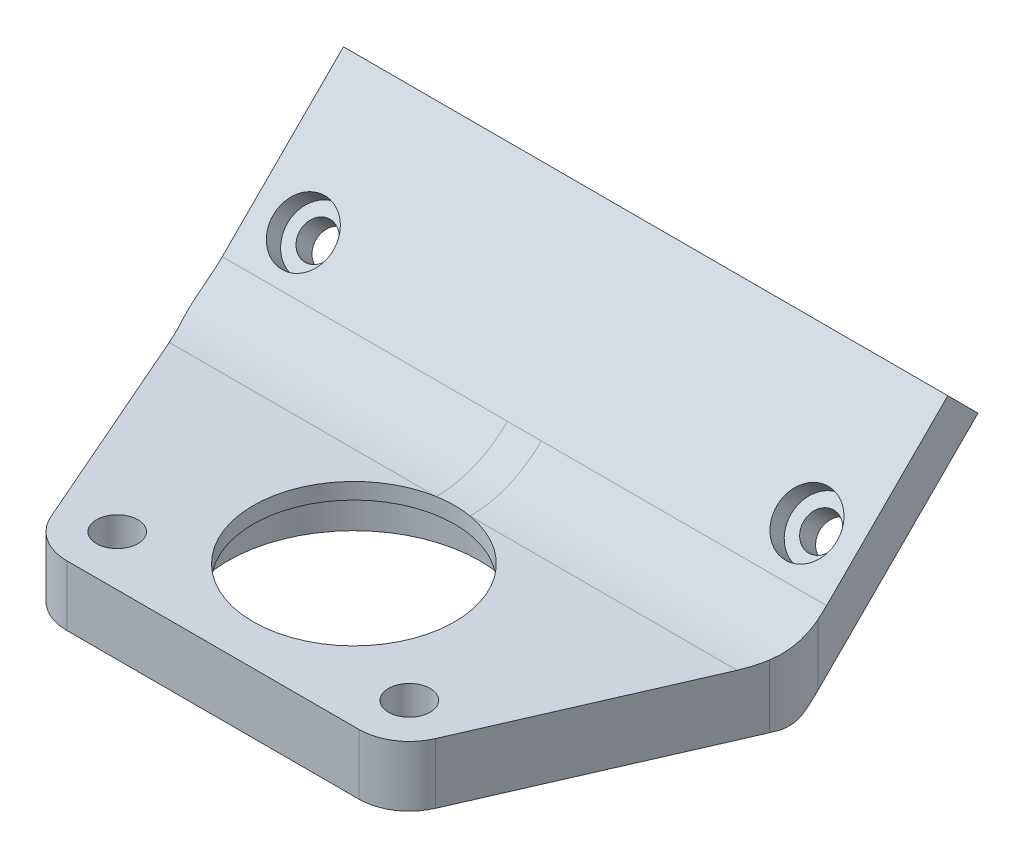
from build123d import *

# Parameters (mm, degrees)
SALIENTE_EXTRUIR1_DEPTH      = 30
SALIENTE_EXTRUIR1_DEPTH_BACK = 30
CROQUIS3_R                   = 1.75
CORTAR_EXTRUIR1_DEPTH        = 4.242641
CROQUIS4_R                   = 3
CORTAR_EXTRUIR2_DEPTH        = 2
CROQUIS5_R                   = 10
CROQUIS5_R_2                 = 1.75
CORTAR_EXTRUIR3_DEPTH        = 6
CROQUIS5_4_R                 = 12.5
CROQUIS5_4_R_2               = 10
CORTAR_EXTRUIR4_DEPTH        = 4.4
REDONDEO1_R                  = 10
REDONDEO2_R                  = 3
REDONDEO3_R                  = 10
CROQUIS6_R                   = 2.06
CORTAR_EXTRUIR5_DEPTH        = 4.2


with BuildPart() as part:
    # Croquis2 → Saliente-Extruir1 (new body, two sides)
    with BuildSketch(Plane(origin=(0, 0, 0), x_dir=(0, 0, -1), z_dir=(1, 0, 0))) as saliente_extruir1_sk:
        Polygon((0, 0), (-28, 0), (-28, 6), (0, 6), (14.960512242, 20.960512242), (17.960512242, 17.960512242), align=None)
    extrude(amount=SALIENTE_EXTRUIR1_DEPTH)
    extrude(saliente_extruir1_sk.sketch, amount=-SALIENTE_EXTRUIR1_DEPTH_BACK)

    # Croquis3 → Cortar-Extruir1 (cut)
    with BuildSketch(Plane(origin=(0, 0, 0), x_dir=(-1, 0, 0), z_dir=(0, -0.707106781, -0.707106781))):
        with Locations((-25, 12.7)):
            Circle(CROQUIS3_R)
        with Locations((25, 12.7)):
            Circle(CROQUIS3_R)
    extrude(amount=-CORTAR_EXTRUIR1_DEPTH, mode=Mode.SUBTRACT)

    # Croquis4 → Cortar-Extruir2 (cut)
    with BuildSketch(Plane(origin=(0, 3, 3), x_dir=(1, 0, 0), z_dir=(0, 0.707106781, 0.707106781))):
        with Locations((-25, 12.7)):
            Circle(CROQUIS4_R)
        with Locations((25, 12.7)):
            Circle(CROQUIS4_R)
    extrude(amount=-CORTAR_EXTRUIR2_DEPTH, mode=Mode.SUBTRACT)

    # Croquis5 → Cortar-Extruir3 (cut)
    with BuildSketch(Plane(origin=(0, 0, 0), x_dir=(-1, 0, 0), z_dir=(0, -1, 0))):
        with Locations((0, -14)):
            Circle(CROQUIS5_R)
        with Locations((14.5, -23)):
            Circle(CROQUIS5_R_2)
        with Locations((-14.5, -23)):
            Circle(CROQUIS5_R_2)
        with BuildLine():
            ThreePointArc((-19.082136833, -25.001005257), (-17.238153914, -27.1836005), (-14.5, -28))
            Line((-14.5, -28), (-30, -28))
            Line((-30, -28), (-30, 0))
            Line((-30, 0), (-19.082136833, -25.001005257))
        make_face()
        with BuildLine():
            Line((30, 0), (19.082136833, -25.001005257))
            ThreePointArc((19.082136833, -25.001005257), (17.238153914, -27.1836005), (14.5, -28))
            Line((14.5, -28), (30, -28))
            Line((30, -28), (30, 0))
        make_face()
    extrude(amount=-CORTAR_EXTRUIR3_DEPTH, mode=Mode.SUBTRACT)

    # Croquis5_4 → Cortar-Extruir4 (cut)
    with BuildSketch(Plane(origin=(0, 0, 0), x_dir=(-1, 0, 0), z_dir=(0, -1, 0))):
        with Locations((0, -14)):
            Circle(CROQUIS5_4_R)
        with Locations((0, -14)):
            Circle(CROQUIS5_4_R_2, mode=Mode.SUBTRACT)
    extrude(amount=-CORTAR_EXTRUIR4_DEPTH, mode=Mode.SUBTRACT)

    # Redondeo1
    redondeo1_edges = [part.edges().sort_by_distance(p)[0] for p in [
        (0, 6, 0),
    ]]
    fillet(redondeo1_edges, radius=REDONDEO1_R)

    # Redondeo2
    redondeo2_edges = [part.edges().sort_by_distance(p)[0] for p in [
        (0, 0, 0),
    ]]
    fillet(redondeo2_edges, radius=REDONDEO2_R)

    # Redondeo3
    redondeo3_edges = [part.edges().sort_by_distance(p)[0] for p in [
        (-30, 3.583831813, 0),
        (30, 3.583831813, 0),
    ]]
    fillet(redondeo3_edges, radius=REDONDEO3_R)

    # Croquis6 → Cortar-Extruir5 (cut)
    with BuildSketch(Plane(origin=(0, 6, 0), x_dir=(1, 0, 0), z_dir=(0, 1, 0))):
        with Locations((-14.5, -23)):
            Circle(CROQUIS6_R)
        with Locations((14.5, -23)):
            Circle(CROQUIS6_R)
    extrude(amount=-CORTAR_EXTRUIR5_DEPTH, mode=Mode.SUBTRACT)


solid = part.part
